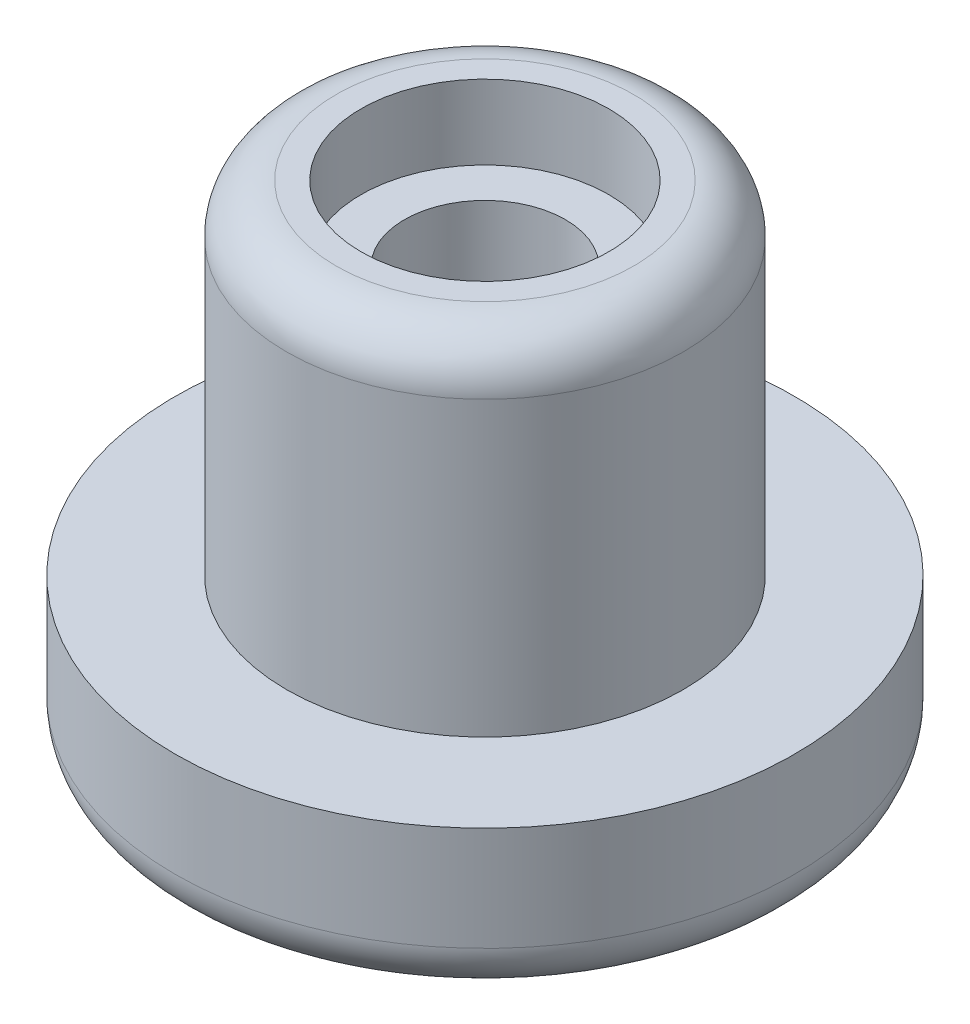
from build123d import *

# Parameters (mm, degrees)
SKETCH1_R           = 31.75
SKETCH1_R_2         = 12.7
BOSS_EXTRUDE1_DEPTH = 15.748
SKETCH2_R           = 20.32
SKETCH2_R_2         = 12.7
BOSS_EXTRUDE2_DEPTH = 35.052
SKETCH3_R           = 12.7
SKETCH3_R_2         = 8.255
BOSS_EXTRUDE3_DEPTH = 43.18
FILLET1_R           = 5.08
FILLET2_R           = 5.08


with BuildPart() as part:
    # Sketch1 → Boss-Extrude1 (new body)
    with BuildSketch(Plane(origin=(0, 0, 0), x_dir=(1, 0, 0), z_dir=(0, 1, 0))):
        Circle(SKETCH1_R)
        Circle(SKETCH1_R_2, mode=Mode.SUBTRACT)
    extrude(amount=BOSS_EXTRUDE1_DEPTH)

    # Sketch2 → Boss-Extrude2 (add)
    with BuildSketch(Plane(origin=(0, 15.748, 0), x_dir=(1, 0, 0), z_dir=(0, 1, 0))):
        Circle(SKETCH2_R)
        Circle(SKETCH2_R_2, mode=Mode.SUBTRACT)
    extrude(amount=BOSS_EXTRUDE2_DEPTH)

    # Fillet1
    fillet1_edges = [part.edges().sort_by_distance(p)[0] for p in [
        (-31.75, 0, 0),
    ]]
    fillet(fillet1_edges, radius=FILLET1_R)

    # Fillet2
    fillet2_edges = [part.edges().sort_by_distance(p)[0] for p in [
        (-20.32, 50.8, 0),
    ]]
    fillet(fillet2_edges, radius=FILLET2_R)


with BuildPart() as body_2:
    # Sketch3 → Boss-Extrude3 (new body)
    with BuildSketch(Plane.XZ):
        Circle(SKETCH3_R)
        Circle(SKETCH3_R_2, mode=Mode.SUBTRACT)
    extrude(amount=-BOSS_EXTRUDE3_DEPTH)


solid = Compound([part.part, body_2.part])
